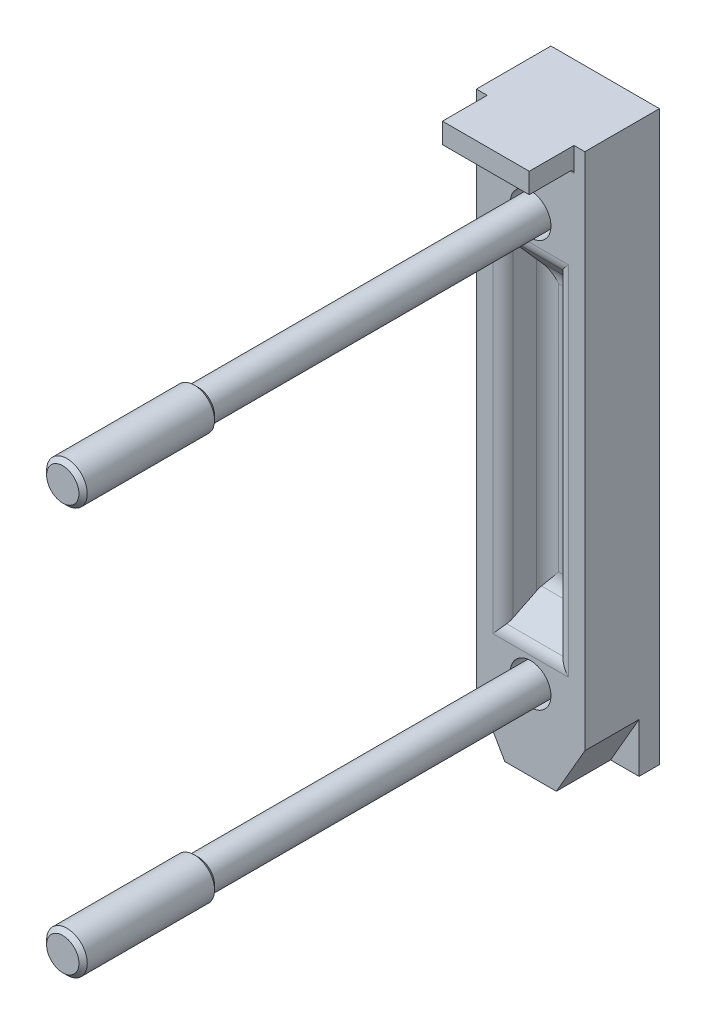
from build123d import *

# Parameters (mm, degrees)
BOSS_EXTRUDE1_DEPTH      = 4
BOSS_EXTRUDE1_DEPTH_BACK = 4
SKETCH1_W                = 5.5
SKETCH1_H                = 41.9
BOSS_EXTRUDE2_DEPTH      = 3.2
BOSS_EXTRUDE2_DEPTH_BACK = 3.2
CUT_EXTRUDE1_DEPTH       = 13.2
CUT_EXTRUDE1_DEPTH_BACK  = 13.2
BOSS_EXTRUDE3_DEPTH      = 2.85
BOSS_EXTRUDE3_DEPTH_BACK = 2.85
BOSS_EXTRUDE4_DEPTH      = 2.85
BOSS_EXTRUDE4_DEPTH_BACK = 2.85
CUT_EXTRUDE2_DEPTH       = 4
CUT_EXTRUDE3_DEPTH       = 1.5
CUT_EXTRUDE3_DEPTH_BACK  = 1.5
CUT_EXTRUDE4_DEPTH       = 1.5
CUT_EXTRUDE4_DEPTH_BACK  = 1.5


with BuildPart() as part:
    # Sketch1 → Boss-Extrude1 (new, two sides: drawn at the far end of the back side and taken through both)
    with BuildSketch(Plane(origin=(0, 0, 0), x_dir=(0, 0, -1), z_dir=(1, 0, 0)).offset(-BOSS_EXTRUDE1_DEPTH_BACK)):
        with Locations((2.75, 15.05)):
            Rectangle(SKETCH1_W, SKETCH1_H)
    extrude(amount=BOSS_EXTRUDE1_DEPTH + BOSS_EXTRUDE1_DEPTH_BACK)

    # Sketch2 → Boss-Extrude2 (add, two sides: drawn at the far end of the back side and taken through both)
    with BuildSketch(Plane(origin=(0, 0, 0), x_dir=(0, 0, -1), z_dir=(1, 0, 0)).offset(-BOSS_EXTRUDE2_DEPTH_BACK)):
        with BuildLine():
            Line((-3.3, 34.5), (-0.3, 34.5))
            ThreePointArc((-0.3, 34.5), (-0.087867966, 34.412132034), (0, 34.2))
            Line((0, 34.2), (0, 36))
            Line((0, 36), (-3.3, 36))
            Line((-3.3, 36), (-3.3, 34.5))
        make_face()
    extrude(amount=BOSS_EXTRUDE2_DEPTH + BOSS_EXTRUDE2_DEPTH_BACK)

    # Sketch3 → Cut-Revolve1 (revolve, cut)
    with BuildSketch(Plane(origin=(0, 0, 0), x_dir=(0, 0, -1), z_dir=(1, 0, 0))):
        Polygon((0, 30), (0, 31.5), (2.4, 31.5), (2.4, 33), (5.5, 33), (5.5, 30), align=None)
    revolve(axis=Axis((0, 30, -5.5), (0, 0, 1)), mode=Mode.SUBTRACT)

    # Sketch4 → Cut-Revolve2 (revolve, cut)
    with BuildSketch(Plane(origin=(0, 0, 0), x_dir=(0, 0, -1), z_dir=(1, 0, 0))):
        Polygon((0, 0), (0, 1.5), (2.4, 1.5), (2.4, 3), (5.5, 3), (5.5, 0), align=None)
    revolve(axis=Axis((0, 0, -5.5), (0, 0, 1)), mode=Mode.SUBTRACT)

    # Sketch5 → Cut-Extrude1 (cut, two sides: drawn at the far end of the back side and taken through both)
    with BuildSketch(Plane(origin=(0, 15, 0), x_dir=(1, 0, 0), z_dir=(0, 1, 0)).offset(-CUT_EXTRUDE1_DEPTH_BACK)):
        with BuildLine():
            Line((-3.5, -2.4), (3.5, -2.4))
            Line((3.5, -2.4), (3.5, 0))
            Line((3.5, 0), (2.787070261, 0))
            ThreePointArc((2.787070261, 0), (2.249770652, 0.156608554), (1.880762474, 0.577381738))
            Line((1.880762474, 0.577381738), (1.327022899, 1.764880088))
            ThreePointArc((1.327022899, 1.764880088), (0.921113903, 2.22773059), (0.330084334, 2.4))
            Line((0.330084334, 2.4), (-0.330084334, 2.4))
            ThreePointArc((-0.330084334, 2.4), (-0.921113903, 2.22773059), (-1.327022899, 1.764880088))
            Line((-1.327022899, 1.764880088), (-1.880762474, 0.577381738))
            ThreePointArc((-1.880762474, 0.577381738), (-2.249770652, 0.156608554), (-2.787070261, 0))
            Line((-2.787070261, 0), (-3.5, 0))
            Line((-3.5, 0), (-3.5, -2.4))
        make_face()
    extrude(amount=CUT_EXTRUDE1_DEPTH + CUT_EXTRUDE1_DEPTH_BACK, mode=Mode.SUBTRACT)

    # Sketch6 → Boss-Extrude3 (add, two sides: drawn at the far end of the back side and taken through both)
    with BuildSketch(Plane(origin=(0, 0, 0), x_dir=(0, 0, -1), z_dir=(1, 0, 0)).offset(-BOSS_EXTRUDE3_DEPTH_BACK)):
        with BuildLine():
            Line((0, 1.626838695), (2.4, 1.626838695))
            Line((2.4, 1.626838695), (2.4, 5.797156532))
            ThreePointArc((2.4, 5.797156532), (2.294462086, 5.198621281), (1.990577775, 4.672278215))
            Line((1.990577775, 4.672278215), (0.304142224, 2.662462588))
            ThreePointArc((0.304142224, 2.662462588), (0.078399593, 2.271464882), (0, 1.826838695))
            Line((0, 1.826838695), (0, 1.626838695))
        make_face()
    extrude(amount=BOSS_EXTRUDE3_DEPTH + BOSS_EXTRUDE3_DEPTH_BACK)

    # Sketch7 → Boss-Extrude4 (add, two sides: drawn at the far end of the back side and taken through both)
    with BuildSketch(Plane(origin=(0, 0, 0), x_dir=(0, 0, -1), z_dir=(1, 0, 0)).offset(-BOSS_EXTRUDE4_DEPTH_BACK)):
        with BuildLine():
            Line((0, 28.373161305), (0, 28.173161305))
            ThreePointArc((0, 28.173161305), (0.078399593, 27.728535118), (0.304142224, 27.337537412))
            Line((0.304142224, 27.337537412), (1.990577775, 25.327721785))
            ThreePointArc((1.990577775, 25.327721785), (2.294462086, 24.801378719), (2.4, 24.202843468))
            Line((2.4, 24.202843468), (2.4, 28.373161305))
            Line((2.4, 28.373161305), (0, 28.373161305))
        make_face()
    extrude(amount=BOSS_EXTRUDE4_DEPTH + BOSS_EXTRUDE4_DEPTH_BACK)

    # Sketch8 → Cut-Extrude2 (cut)
    with BuildSketch(Plane.XY):
        Polygon((-15, -15.264317181), (16.073788546, -15.264317181), (16.073788546, -1.569872981), (4.4, -1.569872981), (1.9, -5.9), (-1.9, -5.9), (-4.4, -1.569872981), (-15, -1.569872981), align=None)
    extrude(amount=-CUT_EXTRUDE2_DEPTH, mode=Mode.SUBTRACT)

    # Sketch9 → Revolve1 (revolve)
    with BuildSketch(Plane(origin=(0, 0, 0), x_dir=(0, 0, -1), z_dir=(1, 0, 0))):
        Polygon((-34.5, 30), (-34.5, 31.1935), (-34.1935, 31.5), (-24.8065, 31.5), (-24.5, 31.1935), (2.4, 31.1935), (2.4, 32.6), (4.5, 32.6), (4.5, 30), align=None)
    revolve(axis=Axis((0, 30, -4.5), (0, 0, 1)))

    # Sketch10 → Revolve2 (revolve)
    with BuildSketch(Plane(origin=(0, 0, 0), x_dir=(0, 0, -1), z_dir=(1, 0, 0))):
        Polygon((-34.5, 0), (-34.5, 1.1935), (-34.1935, 1.5), (-24.8065, 1.5), (-24.5, 1.1935), (2.4, 1.1935), (2.4, 2.6), (4.5, 2.6), (4.5, 0), align=None)
    revolve(axis=Axis((0, 0, -4.5), (0, 0, 1)))

    # Sketch11 → Cut-Extrude3 (cut, two sides: drawn at the far end of the back side and taken through both)
    with BuildSketch(Plane(origin=(0, 0, -4.5), x_dir=(-1, 0, 0), z_dir=(0, 0, -1)).offset(-CUT_EXTRUDE3_DEPTH_BACK)):
        Polygon((0.5, 28), (0.5, 29.5), (2, 29.5), (2, 30.5), (0.5, 30.5), (0.5, 32), (-0.5, 32), (-0.5, 30.5), (-2, 30.5), (-2, 29.5), (-0.5, 29.5), (-0.5, 28), align=None)
    extrude(amount=CUT_EXTRUDE3_DEPTH + CUT_EXTRUDE3_DEPTH_BACK, mode=Mode.SUBTRACT)

    # Sketch12 → Cut-Extrude4 (cut, two sides: drawn at the far end of the back side and taken through both)
    with BuildSketch(Plane(origin=(0, 0, -4.5), x_dir=(-1, 0, 0), z_dir=(0, 0, -1)).offset(-CUT_EXTRUDE4_DEPTH_BACK)):
        Polygon((0.5, -2), (0.5, -0.5), (2, -0.5), (2, 0.5), (0.5, 0.5), (0.5, 2), (-0.5, 2), (-0.5, 0.5), (-2, 0.5), (-2, -0.5), (-0.5, -0.5), (-0.5, -2), align=None)
    extrude(amount=CUT_EXTRUDE4_DEPTH + CUT_EXTRUDE4_DEPTH_BACK, mode=Mode.SUBTRACT)


solid = part.part
